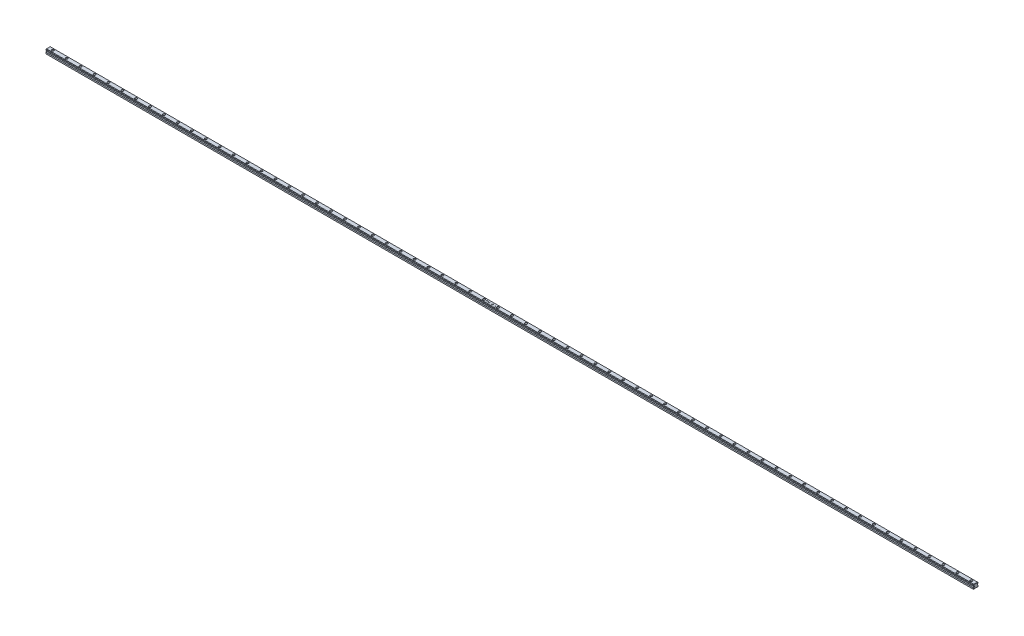
from build123d import *

# Parameters (mm, degrees)
BOSS_EXTRUDE1_DEPTH = 4000
SKETCH2_R           = 4.75
CUT_EXTRUDE1_DEPTH  = 8.5
SKETCH3_R           = 3
CUT_EXTRUDE2_DEPTH  = 10.5
LPATTERN1_COUNT     = 67
LPATTERN1_PITCH     = 60
CUT_EXTRUDE3_DEPTH  = 2
CHAMFER1_SIZE       = 1


with BuildPart() as part:
    # Sketch1 → Boss-Extrude1 (new body)
    with BuildSketch(Plane(origin=(0, 0, 0), x_dir=(0, 0, -1), z_dir=(1, 0, 0))):
        Polygon((-7.993705968, 26.975279321), (8.006294032, 26.975279321), (10.007406223, 24.97416713), (10.007406223, 22.09416713), (7.496841995, 19.598437326), (7.496841995, 17.598437326), (10, 15.095279321), (10, 8.975279321), (-10, 8.975279321), (-10, 15.095279321), (-7.496841995, 17.598437326), (-7.48425393, 19.598437326), (-9.994818158, 22.09416713), (-9.994818158, 24.97416713), align=None)
    extrude(amount=BOSS_EXTRUDE1_DEPTH)

    # Sketch2 → Cut-Extrude1 (cut)
    with BuildSketch(Plane(origin=(0, 26.975279321, 0), x_dir=(1, 0, 0), z_dir=(0, 1, 0))):
        with Locations(Location((3980, 0, 0), (0, 0, 270))):  # turned: the seam where the file's is
            Circle(SKETCH2_R)
    cut_extrude1 = extrude(amount=-CUT_EXTRUDE1_DEPTH, mode=Mode.SUBTRACT)

    # Sketch3 → Cut-Extrude2 (cut, through all)
    with BuildSketch(Plane(origin=(0, 18.475279321, 0), x_dir=(-1, 0, 0), z_dir=(0, 1, 0))):
        with Locations(Location((-3980, 0, 0), (0, 0, 90))):  # turned: the seam where the file's is
            Circle(SKETCH3_R)
    cut_extrude2 = extrude(amount=-CUT_EXTRUDE2_DEPTH, mode=Mode.SUBTRACT)

    # LPattern1: Cut-Extrude1, Cut-Extrude2 ×67
    with Locations(*[(-i * LPATTERN1_PITCH, 0, 0) for i in range(1, LPATTERN1_COUNT)]):
        add(cut_extrude1, mode=Mode.SUBTRACT)
        add(cut_extrude2, mode=Mode.SUBTRACT)

    # Sketch4 → Cut-Extrude3 (cut)
    with BuildSketch(Plane(origin=(0, 26.975279321, 0), x_dir=(1, 0, 0), z_dir=(0, 1, 0))):
        with BuildLine():
            Line((1889.896064723, -1.227528102), (1890.419101582, -1.050144288))
            add(Edge.make_bspline(
                [(1890.419101582, -1.050144288), (1890.466374535, -1.09668759), (1890.559222853, -1.188102808), (1890.7109334, -1.306294357), (1890.867084482, -1.407678245), (1891.029208206, -1.490206083), (1891.196979514, -1.55453553), (1891.370238815, -1.59996868), (1891.549069294, -1.628438067), (1891.670263799, -1.63178414), (1891.731601582, -1.633477622)],
                knots=[0, 0, 0, 0, 1.077107188, 2.115535126, 3.118268307, 4.098136042, 5.065683309, 6.03185857, 7.003903401, 8, 8, 8, 8], degree=3))
            add(Edge.make_bspline(
                [(1891.731601582, -1.633477622), (1891.783994316, -1.632632218), (1891.887377793, -1.630964034), (1892.039839381, -1.614808537), (1892.187592941, -1.590084234), (1892.328302687, -1.554376836), (1892.458866467, -1.511926447), (1892.573969935, -1.459600262), (1892.673368197, -1.401977822), (1892.755430295, -1.336777246), (1892.819815875, -1.26644668), (1892.867383331, -1.193961942), (1892.897152657, -1.118013747), (1892.900712839, -1.066048967), (1892.90247498, -1.040328583)],
                knots=[0, 0, 0, 0, 1.323069028, 2.610733758, 3.868590911, 5.104279844, 6.274831608, 7.33165561, 8.292504985, 9.170248825, 9.96846864, 10.690674306, 11.35193875, 12, 12, 12, 12], degree=3))
            add(Edge.make_bspline(
                [(1892.90247498, -1.040328583), (1892.901725745, -1.025790198), (1892.900210897, -0.99639562), (1892.89003465, -0.952371749), (1892.872756415, -0.908755322), (1892.849597851, -0.864999238), (1892.819073671, -0.822005294), (1892.781121455, -0.780105887), (1892.738080535, -0.737122139), (1892.705476589, -0.710521335), (1892.688632832, -0.696778904)],
                knots=[0, 0, 0, 0, 0.83337383, 1.684965052, 2.575706431, 3.516720359, 4.516646888, 5.589241545, 6.7545609, 8, 8, 8, 8], degree=3))
            add(Edge.make_bspline(
                [(1892.688632832, -0.696778904), (1892.661743173, -0.676602609), (1892.604306143, -0.633505506), (1892.507431397, -0.571269368), (1892.395081901, -0.506774345), (1892.268330074, -0.437648316), (1892.125540936, -0.367618449), (1891.968340151, -0.292788738), (1891.795369747, -0.216131808), (1891.674426542, -0.165132406), (1891.611709755, -0.138685955)],
                knots=[0, 0, 0, 0, 0.66338265, 1.417003019, 2.270697136, 3.220168666, 4.266097518, 5.409252101, 6.656531539, 8, 8, 8, 8], degree=3))
            add(Edge.make_bspline(
                [(1891.611709755, -0.138685955), (1891.549219681, -0.112486783), (1891.429982805, -0.062496324), (1891.26150812, 0.011989941), (1891.111175093, 0.079626993), (1890.979662531, 0.142230393), (1890.8664731, 0.198698791), (1890.771248292, 0.248709488), (1890.695143357, 0.293895082), (1890.651968321, 0.3240766), (1890.63294373, 0.337375744)],
                knots=[0, 0, 0, 0, 1.491842229, 2.846573792, 4.055563426, 5.121205584, 6.053178714, 6.840450705, 7.489057737, 8, 8, 8, 8], degree=3))
            add(Edge.make_bspline(
                [(1890.63294373, 0.337375744), (1890.606706311, 0.35781419), (1890.556066912, 0.39726131), (1890.487605706, 0.460160367), (1890.430030313, 0.525275293), (1890.383192437, 0.591663096), (1890.345459875, 0.659035456), (1890.319798917, 0.728384944), (1890.302407934, 0.798793432), (1890.300739496, 0.846523499), (1890.299910877, 0.870228308)],
                knots=[0, 0, 0, 0, 1.223434175, 2.36128301, 3.415332829, 4.41497796, 5.346266783, 6.247042329, 7.129405678, 8, 8, 8, 8], degree=3))
            add(Edge.make_bspline(
                [(1890.299910877, 0.870228308), (1890.300389567, 0.888962318), (1890.301340827, 0.926190838), (1890.310893289, 0.98148247), (1890.32643813, 1.035436914), (1890.347487119, 1.088458408), (1890.375099351, 1.139893206), (1890.409038861, 1.189649634), (1890.448709135, 1.238395474), (1890.494111172, 1.285840258), (1890.545246587, 1.331290591), (1890.60171828, 1.374082402), (1890.662899544, 1.41469087), (1890.728590469, 1.453481009), (1890.800112803, 1.488415965), (1890.876292873, 1.521036966), (1890.95705589, 1.552170801), (1891.072028071, 1.589558682), (1891.22319441, 1.628617709), (1891.411712605, 1.663289134), (1891.60826162, 1.682735893), (1891.741610094, 1.685585829), (1891.809426102, 1.687035199)],
                knots=[0, 0, 0, 0, 0.598707129, 1.189760184, 1.788327325, 2.392098687, 3.010723788, 3.651310834, 4.315532933, 5.018652768, 5.749244697, 6.501203356, 7.282744643, 8.096779319, 8.939146057, 9.826379183, 10.746714686, 11.706366205, 13.691518466, 15.735244642, 17.831106148, 20, 20, 20, 20], degree=3))
            add(Edge.make_bspline(
                [(1891.809426102, 1.687035199), (1891.881470063, 1.685844073), (1892.02381516, 1.683490636), (1892.233273114, 1.660160045), (1892.43578968, 1.623891863), (1892.599701113, 1.581319596), (1892.728778976, 1.538032828), (1892.82671277, 1.499677621), (1892.925738617, 1.454124728), (1893.026682099, 1.404101254), (1893.128496734, 1.346915171), (1893.231687321, 1.283501654), (1893.33660451, 1.214503782), (1893.405821265, 1.164717039), (1893.440936518, 1.139459077)],
                knots=[0, 0, 0, 0, 1.478004001, 2.920253407, 4.319170524, 5.69771349, 6.390841341, 7.112265038, 7.854931021, 8.627102237, 9.423702556, 10.250387688, 11.112381392, 12, 12, 12, 12], degree=3))
            Line((1893.440936518, 1.139459077), (1892.938933313, 0.924214686))
            add(Edge.make_bspline(
                [(1892.938933313, 0.924214686), (1892.910025387, 0.943951177), (1892.853760181, 0.982365475), (1892.770418863, 1.036708843), (1892.689666408, 1.084808026), (1892.612791054, 1.128578487), (1892.538797816, 1.16653657), (1892.468311871, 1.199634545), (1892.400639101, 1.227148957), (1892.314638414, 1.257099184), (1892.20625024, 1.285838569), (1892.072637068, 1.31028641), (1891.933402933, 1.325362416), (1891.838677606, 1.327151054), (1891.790495813, 1.32806084)],
                knots=[0, 0, 0, 0, 1.015813668, 1.977138194, 2.886731694, 3.743135713, 4.543941158, 5.299495916, 6.002279374, 6.662923217, 7.941265333, 9.251593154, 10.602029956, 12, 12, 12, 12], degree=3))
            add(Edge.make_bspline(
                [(1891.790495813, 1.32806084), (1891.759641502, 1.3275823), (1891.699050445, 1.326642554), (1891.610283038, 1.32148832), (1891.526090168, 1.310704233), (1891.446334734, 1.296559378), (1891.370417276, 1.279620917), (1891.299169429, 1.256886083), (1891.231960521, 1.23113254), (1891.170035637, 1.200978506), (1891.11371312, 1.168826061), (1891.064648462, 1.133813579), (1891.022127669, 1.098051359), (1890.988172983, 1.05871789), (1890.960801946, 1.018313606), (1890.942791403, 0.975029107), (1890.929711891, 0.930824401), (1890.928647801, 0.900237917), (1890.928116005, 0.884951866)],
                knots=[0, 0, 0, 0, 1.399612593, 2.748530234, 4.030476182, 5.24693714, 6.422051271, 7.555252122, 8.635971983, 9.683749459, 10.676457576, 11.573553606, 12.41520041, 13.18902876, 13.924056968, 14.61722835, 15.308939227, 16, 16, 16, 16], degree=3))
            add(Edge.make_bspline(
                [(1890.928116005, 0.884951866), (1890.9293334, 0.86616398), (1890.931792523, 0.828212658), (1890.947815447, 0.77170082), (1890.975414511, 0.716905412), (1891.012650704, 0.660965664), (1891.065789266, 0.60558749), (1891.135303334, 0.549346931), (1891.221539417, 0.49035324), (1891.286112363, 0.452844855), (1891.320744211, 0.432728308)],
                knots=[0, 0, 0, 0, 0.718244953, 1.450846875, 2.225953974, 3.056001156, 4.010382228, 5.146202887, 6.469447763, 8, 8, 8, 8], degree=3))
            add(Edge.make_bspline(
                [(1891.320744211, 0.432728308), (1891.333781963, 0.425850855), (1891.365316897, 0.409216083), (1891.42236404, 0.383023463), (1891.49699487, 0.350314835), (1891.588352025, 0.309527737), (1891.697431013, 0.262390353), (1891.824183929, 0.209618888), (1891.96803383, 0.149051675), (1892.06976102, 0.106670982), (1892.123528666, 0.084270776)],
                knots=[0, 0, 0, 0, 0.404103783, 0.977422063, 1.720433544, 2.638463186, 3.720505373, 4.978428416, 6.402956073, 8, 8, 8, 8], degree=3))
            add(Edge.make_bspline(
                [(1892.123528666, 0.084270776), (1892.188135811, 0.05669738), (1892.31267689, 0.003545047), (1892.490920765, -0.077070401), (1892.65350429, -0.154970604), (1892.799587122, -0.231756449), (1892.930424255, -0.305041582), (1893.04555805, -0.376234887), (1893.144949283, -0.44531309), (1893.228791241, -0.513380367), (1893.299945837, -0.580239771), (1893.361249955, -0.646173574), (1893.413652494, -0.711936179), (1893.455948176, -0.778296933), (1893.48979146, -0.844475739), (1893.51265315, -0.911358593), (1893.527721638, -0.97819765), (1893.529696864, -1.022956176), (1893.530680108, -1.045236436)],
                knots=[0, 0, 0, 0, 1.783442384, 3.437883494, 4.966524892, 6.359936173, 7.627321433, 8.77331101, 9.795597996, 10.698224182, 11.512591981, 12.27259334, 12.982459405, 13.644167745, 14.26777206, 14.8645156, 15.434769434, 16, 16, 16, 16], degree=3))
            add(Edge.make_bspline(
                [(1893.530680108, -1.045236436), (1893.529327863, -1.076724041), (1893.526621578, -1.139741029), (1893.500416141, -1.231831526), (1893.459974935, -1.320847397), (1893.402686792, -1.406284731), (1893.329726883, -1.488627056), (1893.240488586, -1.56700069), (1893.135611948, -1.642284238), (1893.016323702, -1.713279161), (1892.885643909, -1.778285313), (1892.746959609, -1.836324608), (1892.601056974, -1.884356445), (1892.44806655, -1.923680897), (1892.28833173, -1.954244725), (1892.121713127, -1.976722145), (1891.9482422, -1.99028669), (1891.830250655, -1.991721368), (1891.770163281, -1.992451981)],
                knots=[0, 0, 0, 0, 0.693474943, 1.38786997, 2.096467395, 2.844638244, 3.648632338, 4.518152449, 5.460118056, 6.494171073, 7.578298796, 8.678901884, 9.809221544, 10.965140982, 12.162825778, 13.396325435, 14.674074748, 16, 16, 16, 16], degree=3))
            add(Edge.make_bspline(
                [(1891.770163281, -1.992451981), (1891.723640199, -1.991946027), (1891.631452156, -1.990943454), (1891.494900692, -1.981957611), (1891.361434725, -1.969349396), (1891.231508739, -1.949097926), (1891.104591173, -1.924991374), (1890.98104313, -1.89476402), (1890.860983754, -1.859013673), (1890.744121199, -1.817572058), (1890.629704601, -1.769733122), (1890.517872874, -1.714317419), (1890.408037735, -1.65198296), (1890.301398428, -1.581117035), (1890.195916323, -1.504201408), (1890.093149515, -1.419211541), (1889.992270147, -1.327246121), (1889.928429464, -1.261074524), (1889.896064723, -1.227528102)],
                knots=[0, 0, 0, 0, 1.069376373, 2.119027998, 3.144925753, 4.150188629, 5.140655191, 6.114057022, 7.07277299, 8.019292695, 8.963231928, 9.921932842, 10.886876106, 11.864405956, 12.863779483, 13.886704494, 14.928641489, 16, 16, 16, 16], degree=3))
        make_face()
        Polygon((1895.312090364, 1.597291609), (1895.940295493, 1.597291609), (1895.940295493, 0.161394173), (1898.991577544, 0.161394173), (1898.991577544, 1.597291609), (1899.619782672, 1.597291609), (1899.619782672, -1.902708391), (1898.991577544, -1.902708391), (1898.991577544, -0.197580186), (1895.940295493, -0.197580186), (1895.940295493, -1.902708391), (1895.312090364, -1.902708391), align=None)
        Polygon((1901.715295493, -1.902708391), (1901.715295493, 1.597291609), (1901.847807512, 1.597291609), (1905.888372416, -1.033317365), (1905.888372416, 1.597291609), (1906.516577544, 1.597291609), (1906.516577544, -1.902708391), (1906.373548698, -1.902708391), (1902.343500621, 0.720188244), (1902.343500621, -1.902708391), align=None)
        with BuildLine():
            Line((1911.874269852, 0.520368532), (1911.246064723, 0.520368532))
            add(Edge.make_bspline(
                [(1911.246064723, 0.520368532), (1911.249756449, 0.562154674), (1911.257070293, 0.644939088), (1911.289399581, 0.765375482), (1911.339455122, 0.87953181), (1911.405728784, 0.988239535), (1911.489995317, 1.090462575), (1911.590039832, 1.187798302), (1911.708310304, 1.277988516), (1911.841617292, 1.361883101), (1911.987279649, 1.43864437), (1912.143123711, 1.505007405), (1912.307250253, 1.561067509), (1912.479342697, 1.607505557), (1912.660036185, 1.642881961), (1912.848915818, 1.668793422), (1913.046277317, 1.684493943), (1913.180664424, 1.686177161), (1913.249169691, 1.687035199)],
                knots=[0, 0, 0, 0, 0.792333241, 1.569727201, 2.345812882, 3.143394519, 3.969819973, 4.845153681, 5.778005485, 6.777522579, 7.821592192, 8.889058324, 9.978091973, 11.099762135, 12.258023523, 13.458374983, 14.704379431, 16, 16, 16, 16], degree=3))
            add(Edge.make_bspline(
                [(1913.249169691, 1.687035199), (1913.316738377, 1.686134726), (1913.448770812, 1.684375159), (1913.64166429, 1.669460902), (1913.824752181, 1.645077713), (1913.997949887, 1.611143965), (1914.161126541, 1.566719731), (1914.314789516, 1.513874255), (1914.458312073, 1.449925769), (1914.590581973, 1.376466931), (1914.710845389, 1.297833137), (1914.815023147, 1.213121172), (1914.904466415, 1.126321908), (1914.977814917, 1.035284596), (1915.034536824, 0.940113368), (1915.075021704, 0.841153426), (1915.100973586, 0.738813616), (1915.103683188, 0.66892353), (1915.105039082, 0.633950263)],
                knots=[0, 0, 0, 0, 1.386812386, 2.709897552, 3.968433488, 5.176445875, 6.329713579, 7.43724515, 8.508837806, 9.55023929, 10.540148442, 11.454198015, 12.302267464, 13.094177349, 13.846979117, 14.56768537, 15.283264257, 16, 16, 16, 16], degree=3))
            add(Edge.make_bspline(
                [(1915.105039082, 0.633950263), (1915.104504299, 0.609120758), (1915.103438449, 0.559634332), (1915.090520895, 0.486469729), (1915.071988548, 0.414107834), (1915.044043228, 0.343506082), (1915.009680841, 0.273257314), (1914.966459931, 0.204973304), (1914.916673095, 0.136959636), (1914.856677438, 0.070277435), (1914.786999504, 0.00017135), (1914.702351494, -0.072990904), (1914.604825685, -0.153806818), (1914.491187813, -0.238633284), (1914.364689082, -0.330965808), (1914.222126, -0.427128416), (1914.066499068, -0.531328302), (1913.956319551, -0.600543114), (1913.899109595, -0.636482429)],
                knots=[0, 0, 0, 0, 0.65272305, 1.300909207, 1.949912014, 2.615861563, 3.295309181, 4.005334899, 4.739771894, 5.511094034, 6.363568823, 7.339726715, 8.454131166, 9.696633352, 11.070948895, 12.57570215, 14.221956897, 16, 16, 16, 16], degree=3))
            Line((1913.899109595, -0.636482429), (1912.444982993, -1.543734032))
            Line((1912.444982993, -1.543734032), (1915.194782672, -1.543734032))
            Line((1915.194782672, -1.543734032), (1915.194782672, -1.902708391))
            Line((1915.194782672, -1.902708391), (1911.021705749, -1.902708391))
            Line((1911.021705749, -1.902708391), (1913.344522255, -0.454190763))
            add(Edge.make_bspline(
                [(1913.344522255, -0.454190763), (1913.40092868, -0.419736591), (1913.508962226, -0.353747542), (1913.662542747, -0.257015676), (1913.800712619, -0.167318903), (1913.923778738, -0.084835958), (1914.030679802, -0.008612264), (1914.122626263, 0.060216839), (1914.199072162, 0.122223198), (1914.261803939, 0.178639288), (1914.313508345, 0.232178259), (1914.356822966, 0.285230248), (1914.393903481, 0.339030239), (1914.424072225, 0.393477826), (1914.447434389, 0.448749458), (1914.4646874, 0.50455787), (1914.474563311, 0.561384461), (1914.476080314, 0.599560087), (1914.476833954, 0.618525584)],
                knots=[0, 0, 0, 0, 1.959780506, 3.753509237, 5.381474594, 6.844063042, 8.145817243, 9.27394652, 10.249065673, 11.063394855, 11.774033949, 12.453692358, 13.09181049, 13.709004761, 14.295890523, 14.868027222, 15.437640518, 16, 16, 16, 16], degree=3))
            add(Edge.make_bspline(
                [(1914.476833954, 0.618525584), (1914.475764785, 0.642459428), (1914.473641258, 0.689995583), (1914.45619197, 0.759817361), (1914.426722837, 0.826514637), (1914.386087317, 0.890763878), (1914.334657563, 0.952681423), (1914.271073373, 1.011202397), (1914.196290656, 1.066994552), (1914.11158117, 1.120512519), (1914.018299827, 1.168837329), (1913.919344123, 1.211899428), (1913.815113709, 1.247454875), (1913.705986433, 1.27696389), (1913.591507875, 1.300243855), (1913.471767048, 1.315839446), (1913.347034839, 1.326032132), (1913.262278067, 1.327375325), (1913.219021454, 1.32806084)],
                knots=[0, 0, 0, 0, 0.727674161, 1.445268471, 2.174643741, 2.938338395, 3.751529703, 4.617060701, 5.561567616, 6.587626865, 7.662866366, 8.755512416, 9.868864306, 11.011012212, 12.193823562, 13.420964697, 14.68375909, 16, 16, 16, 16], degree=3))
            add(Edge.make_bspline(
                [(1913.219021454, 1.32806084), (1913.173666243, 1.327343577), (1913.084717609, 1.325936914), (1912.95429467, 1.316219344), (1912.829787897, 1.299311362), (1912.711074125, 1.276232731), (1912.597996152, 1.247125449), (1912.49086814, 1.210559097), (1912.389764589, 1.166885113), (1912.294769759, 1.117708253), (1912.207553808, 1.062335775), (1912.129226873, 1.001645775), (1912.061555728, 0.934492025), (1912.003384583, 0.862509883), (1911.955062211, 0.784977594), (1911.918368286, 0.701375599), (1911.889105418, 0.613264022), (1911.879265306, 0.551648444), (1911.874269852, 0.520368532)],
                knots=[0, 0, 0, 0, 1.268457268, 2.48764228, 3.65514874, 4.780640362, 5.868197746, 6.918240767, 7.94299768, 8.945777236, 9.906786621, 10.828609131, 11.711392697, 12.56682027, 13.412099109, 14.257605361, 15.11545176, 16, 16, 16, 16], degree=3))
        make_face()
        with BuildLine():
            add(Edge.make_bspline(
                [(1916.303116005, -0.154110634), (1916.303937176, -0.097999323), (1916.305533559, 0.011082864), (1916.317487725, 0.170050418), (1916.337353518, 0.319297094), (1916.366159819, 0.458654061), (1916.402440956, 0.588091755), (1916.446402545, 0.707950504), (1916.498966673, 0.817991767), (1916.56061082, 0.918406078), (1916.63018636, 1.010433232), (1916.705027687, 1.097026076), (1916.787193277, 1.177272411), (1916.875310949, 1.252619204), (1916.971208118, 1.321037812), (1917.072970733, 1.384711741), (1917.18225439, 1.440940797), (1917.296873364, 1.493191039), (1917.417175829, 1.537876115), (1917.540938658, 1.578440487), (1917.668366268, 1.611796471), (1917.799444008, 1.639136051), (1917.933706176, 1.660913868), (1918.071755144, 1.676265552), (1918.213074089, 1.685597244), (1918.308543747, 1.686553056), (1918.356701743, 1.687035199)],
                knots=[0, 0, 0, 0, 1.282967082, 2.494129101, 3.642908349, 4.723472607, 5.745286235, 6.714148057, 7.639158742, 8.529111643, 9.40339502, 10.274618849, 11.143775093, 12.027157371, 12.92297944, 13.834993564, 14.769602522, 15.731111542, 16.713729643, 17.702374532, 18.70824467, 19.723848738, 20.763189752, 21.817196516, 22.89892304, 24, 24, 24, 24], degree=3))
            add(Edge.make_bspline(
                [(1918.356701743, 1.687035199), (1918.405560963, 1.686554599), (1918.502431772, 1.685601736), (1918.645847009, 1.676244308), (1918.78578373, 1.661006553), (1918.922087847, 1.638926938), (1919.055145356, 1.61207386), (1919.18471261, 1.578057687), (1919.310778179, 1.538476556), (1919.432703648, 1.491771644), (1919.550540156, 1.440974598), (1919.661431138, 1.381225255), (1919.766709401, 1.317199166), (1919.865688782, 1.246545699), (1919.958014373, 1.169656323), (1920.043996819, 1.08623445), (1920.124188267, 0.997391642), (1920.197278258, 0.901476786), (1920.264039771, 0.799041178), (1920.320595227, 0.687388985), (1920.36927041, 0.567889288), (1920.408132122, 0.439623856), (1920.439270027, 0.303085649), (1920.460241581, 0.15793916), (1920.474160573, 0.004614819), (1920.47550425, -0.100325372), (1920.476192929, -0.154110634)],
                knots=[0, 0, 0, 0, 1.103510234, 2.187876263, 3.244794759, 4.281910747, 5.30583003, 6.309670649, 7.306393076, 8.288795308, 9.257888416, 10.202517294, 11.131438941, 12.039670126, 12.946734589, 13.84273273, 14.743647114, 15.647449077, 16.564109786, 17.501408675, 18.469940868, 19.475168584, 20.525302184, 21.63023833, 22.785420029, 24, 24, 24, 24], degree=3))
            add(Edge.make_bspline(
                [(1920.476192929, -0.154110634), (1920.475521457, -0.207664254), (1920.474211486, -0.312141864), (1920.460060692, -0.464705805), (1920.439938892, -0.609163308), (1920.40974175, -0.745158895), (1920.370491756, -0.872458512), (1920.322617418, -0.991574401), (1920.266913215, -1.102679957), (1920.201574379, -1.204990999), (1920.129050265, -1.299966381), (1920.049416396, -1.388423657), (1919.963653274, -1.471327556), (1919.871679696, -1.548858839), (1919.772578686, -1.619610338), (1919.66693576, -1.684089396), (1919.555231176, -1.743359158), (1919.436941863, -1.795510242), (1919.31357967, -1.841347597), (1919.186986253, -1.882405011), (1919.056634421, -1.915683363), (1918.923377083, -1.943979172), (1918.786467544, -1.965698867), (1918.646050692, -1.980703531), (1918.502462281, -1.991260218), (1918.405566042, -1.992052458), (1918.356701743, -1.992451981)],
                knots=[0, 0, 0, 0, 1.209993238, 2.360572526, 3.460142457, 4.504563743, 5.505318173, 6.467527039, 7.402963226, 8.310007459, 9.20692164, 10.100891458, 10.997401168, 11.900932102, 12.817050905, 13.746502919, 14.696338221, 15.672951416, 16.665798934, 17.669726482, 18.679252079, 19.704831077, 20.747755368, 21.810527485, 22.895859718, 24, 24, 24, 24], degree=3))
            add(Edge.make_bspline(
                [(1918.356701743, -1.992451981), (1918.308543988, -1.991967699), (1918.213074806, -1.991007647), (1918.071752364, -1.981707058), (1917.934211731, -1.966296576), (1917.800437332, -1.945054227), (1917.669869338, -1.918956686), (1917.543188318, -1.885001625), (1917.420141195, -1.845632798), (1917.300952433, -1.801179336), (1917.186975392, -1.750016009), (1917.078612171, -1.693552191), (1916.977135122, -1.629904866), (1916.882083368, -1.560719869), (1916.792985936, -1.486065263), (1916.71068454, -1.405192273), (1916.635080743, -1.317972522), (1916.564837474, -1.225223855), (1916.502424728, -1.124145026), (1916.449364273, -1.013236653), (1916.403785634, -0.893184369), (1916.366838603, -0.763677806), (1916.338021051, -0.624717399), (1916.318412177, -0.476135975), (1916.305300437, -0.318173293), (1916.303856969, -0.209760988), (1916.303116005, -0.154110634)],
                knots=[0, 0, 0, 0, 1.102535284, 2.185694505, 3.241097251, 4.270402722, 5.286267283, 6.288296399, 7.271517228, 8.243534689, 9.199242523, 10.130350055, 11.039029967, 11.939177337, 12.820275299, 13.69815002, 14.578077261, 15.461009477, 16.359501167, 17.292881644, 18.271797408, 19.29643259, 20.373188608, 21.5181874, 22.726032526, 24, 24, 24, 24], degree=3))
        make_face()
        with BuildLine():
            add(Edge.make_bspline(
                [(1916.931321134, -0.152708391), (1916.931821535, -0.199464117), (1916.932793176, -0.290250861), (1916.941362509, -0.422204107), (1916.954883209, -0.545377191), (1916.974828538, -0.659512116), (1916.998642687, -0.765237631), (1917.029785879, -0.861835154), (1917.06490551, -0.950364229), (1917.107862368, -1.029761725), (1917.155926477, -1.102406371), (1917.208916006, -1.169933332), (1917.266325262, -1.233734481), (1917.330611601, -1.291596246), (1917.399461431, -1.345726442), (1917.473237321, -1.395860463), (1917.552940554, -1.440659183), (1917.665790602, -1.494436092), (1917.813109607, -1.550250161), (1917.996190168, -1.598057359), (1918.184188598, -1.627792126), (1918.311488068, -1.631572671), (1918.375632031, -1.633477622)],
                knots=[0, 0, 0, 0, 1.18389371, 2.298795565, 3.347117478, 4.320095053, 5.231683865, 6.088916345, 6.887906741, 7.639878361, 8.370325171, 9.091312211, 9.811886197, 10.540820967, 11.278425448, 12.028578287, 12.797158233, 13.591289762, 15.192784684, 16.777570575, 18.376274528, 20, 20, 20, 20], degree=3))
            add(Edge.make_bspline(
                [(1918.375632031, -1.633477622), (1918.440257077, -1.631933774), (1918.567831405, -1.628886112), (1918.75534847, -1.598387108), (1918.936833058, -1.552804018), (1919.081830257, -1.497871726), (1919.192135563, -1.444651156), (1919.270538373, -1.400861945), (1919.342691608, -1.350578452), (1919.410166631, -1.296497698), (1919.473314347, -1.238388891), (1919.529636589, -1.174041627), (1919.582375864, -1.10623284), (1919.612167499, -1.05723309), (1919.627134435, -1.032616243)],
                knots=[0, 0, 0, 0, 1.60057579, 3.159647789, 4.696696728, 6.233035977, 6.992153522, 7.731497408, 8.456172134, 9.16905895, 9.874017323, 10.579736887, 11.286478012, 12, 12, 12, 12], degree=3))
            add(Edge.make_bspline(
                [(1919.627134435, -1.032616243), (1919.644933042, -1.001563874), (1919.680630241, -0.939284696), (1919.725347082, -0.840418921), (1919.76326538, -0.737296015), (1919.793913523, -0.629404556), (1919.818934825, -0.517140052), (1919.835027542, -0.399631005), (1919.846118567, -0.277720547), (1919.847358403, -0.194801757), (1919.8479878, -0.152708391)],
                knots=[0, 0, 0, 0, 0.934788751, 1.874828719, 2.831170889, 3.803369388, 4.803550534, 5.833852178, 6.900364402, 8, 8, 8, 8], degree=3))
            add(Edge.make_bspline(
                [(1919.8479878, -0.152708391), (1919.847599866, -0.110618987), (1919.846840105, -0.028187772), (1919.836497444, 0.092320985), (1919.821175905, 0.206990801), (1919.800662236, 0.316120997), (1919.772343889, 0.419043704), (1919.738826693, 0.516437025), (1919.698864992, 0.607966504), (1919.652288196, 0.693412121), (1919.601376239, 0.77362131), (1919.544661091, 0.847592751), (1919.483801021, 0.916560694), (1919.417671031, 0.979602155), (1919.347316779, 1.037525675), (1919.271997763, 1.089519237), (1919.191966979, 1.135772701), (1919.079494483, 1.189746434), (1918.932977554, 1.244336393), (1918.751799081, 1.293864428), (1918.565117831, 1.322027871), (1918.439055698, 1.326041517), (1918.375632031, 1.32806084)],
                knots=[0, 0, 0, 0, 1.065067151, 2.085911725, 3.058894148, 3.9928253, 4.894034243, 5.758356856, 6.598056611, 7.418596715, 8.219387875, 9.000266746, 9.775478525, 10.545322475, 11.310332907, 12.079926808, 12.859168262, 13.647606467, 15.235209525, 16.809353949, 18.39474023, 20, 20, 20, 20], degree=3))
            add(Edge.make_bspline(
                [(1918.375632031, 1.32806084), (1918.311038087, 1.326063294), (1918.183109147, 1.322107134), (1917.994121886, 1.293874273), (1917.811819353, 1.244801319), (1917.665648216, 1.189550423), (1917.553990363, 1.136611243), (1917.475261799, 1.091589511), (1917.401594714, 1.041975753), (1917.333390192, 0.987322177), (1917.269060945, 0.929787394), (1917.211788339, 0.865677339), (1917.157960256, 0.79863443), (1917.10997227, 0.725728724), (1917.067102477, 0.646215911), (1917.031275942, 0.558058703), (1916.999142796, 0.461547235), (1916.974667469, 0.355578858), (1916.955058698, 0.241101555), (1916.941250604, 0.117734928), (1916.932816944, -0.014468375), (1916.931829566, -0.105720028), (1916.931321134, -0.152708391)],
                knots=[0, 0, 0, 0, 1.635744711, 3.23960843, 4.826099566, 6.409086667, 7.190080903, 7.953609142, 8.703852785, 9.436901454, 10.165924459, 10.886585668, 11.61131899, 12.341854219, 13.093916863, 13.895258721, 14.748786112, 15.667605037, 16.646533431, 17.689101304, 18.810045159, 20, 20, 20, 20], degree=3))
        make_face(mode=Mode.SUBTRACT)
        Polygon((1927.449269852, 1.597291609), (1930.321064723, -1.902708391), (1929.62835639, -1.902708391), (1928.707783473, -0.780913519), (1926.071565525, -0.780913519), (1925.136970172, -1.902708391), (1924.442859595, -1.902708391), (1927.359526262, 1.597291609), align=None)
        Polygon((1927.399490204, 0.813437442), (1926.370243409, -0.42193916), (1928.41331232, -0.42193916), align=None, mode=Mode.SUBTRACT)
    extrude(amount=-CUT_EXTRUDE3_DEPTH, mode=Mode.SUBTRACT)

    # Chamfer1
    chamfer1_edges = [part.edges().sort_by_distance(p)[0] for p in [
        (4000, 20.846302228, 8.739536044),
        (0, 26.975279321, -0.006294032),
        (0, 25.974723225, -9.006850128),
        (4000, 18.598437326, 7.490547962),
        (0, 23.53416713, -10.007406223),
        (0, 20.846302228, -8.752124109),
        (0, 18.598437326, -7.496841995),
        (0, 16.346858323, -8.748420997),
        (0, 12.035279321, -10),
        (0, 8.975279321, 0),
        (0, 12.035279321, 10),
        (4000, 16.346858323, 8.748420997),
        (0, 16.346858323, 8.748420997),
        (0, 18.598437326, 7.490547962),
        (0, 20.846302228, 8.739536044),
        (0, 23.53416713, 9.994818158),
        (0, 25.974723225, 8.994262063),
        (4000, 12.035279321, 10),
        (4000, 8.975279321, 0),
        (4000, 12.035279321, -10),
        (4000, 16.346858323, -8.748420997),
        (4000, 18.598437326, -7.496841995),
        (4000, 20.846302228, -8.752124109),
        (4000, 23.53416713, -10.007406223),
        (4000, 25.974723225, 8.994262063),
        (4000, 25.974723225, -9.006850128),
        (4000, 26.975279321, -0.006294032),
        (4000, 23.53416713, 9.994818158),
    ]]
    chamfer(chamfer1_edges, length=CHAMFER1_SIZE)


solid = part.part
